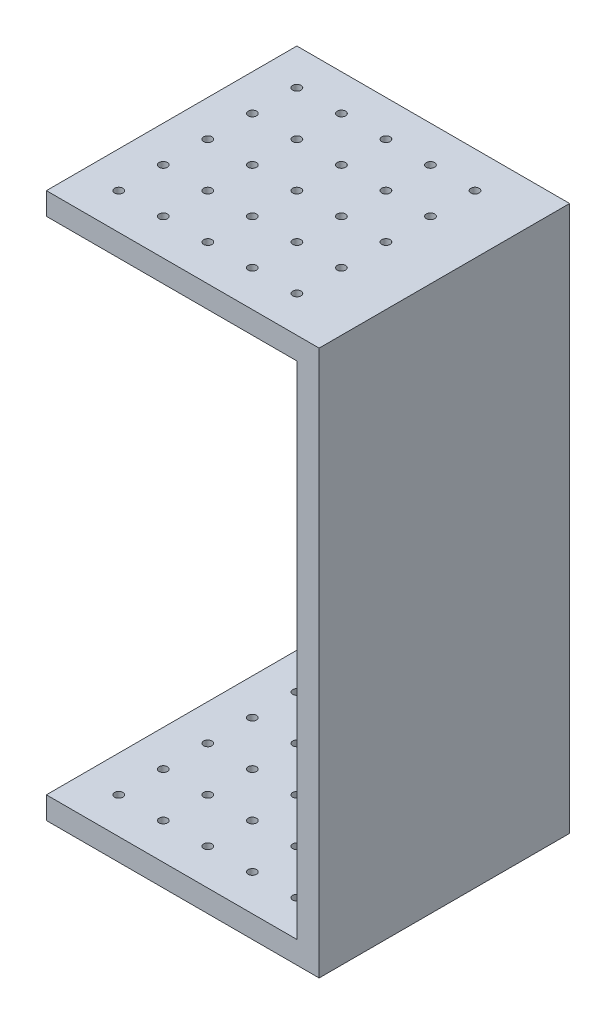
from build123d import *

# Parameters (mm, degrees)
SKETCH1_W            = 24.5
SKETCH1_H            = 22.5
BOSS_EXTRUDE1_DEPTH  = 2
SKETCH2_W            = 2
SKETCH2_H            = 22.5
BOSS_EXTRUDE2_DEPTH  = 45
SKETCH4_W            = 24.5
SKETCH4_H            = 22.5
BOSS_EXTRUDE3_DEPTH  = 2
SKETCH3_R            = 0.375
CUT_EXTRUDE1_DEPTH   = 50
LPATTERN1_COUNT      = 5
LPATTERN1_PITCH      = 4
LPATTERN1_COUNT_DIR2 = 5
LPATTERN1_PITCH_DIR2 = 4


with BuildPart() as part:
    # Sketch1 → Boss-Extrude1 (new body)
    with BuildSketch(Plane(origin=(0, 0, 0), x_dir=(1, 0, 0), z_dir=(0, 1, 0))):
        Rectangle(SKETCH1_W, SKETCH1_H)
    extrude(amount=BOSS_EXTRUDE1_DEPTH)

    # Sketch2 → Boss-Extrude2 (add)
    with BuildSketch(Plane(origin=(0, 2, 0), x_dir=(1, 0, 0), z_dir=(0, 1, 0))):
        with Locations((11.25, 0)):
            Rectangle(SKETCH2_W, SKETCH2_H)
    extrude(amount=BOSS_EXTRUDE2_DEPTH)

    # Sketch4 → Boss-Extrude3 (add)
    with BuildSketch(Plane(origin=(0, 47, 0), x_dir=(1, 0, 0), z_dir=(0, 1, 0))):
        Rectangle(SKETCH4_W, SKETCH4_H)
    extrude(amount=BOSS_EXTRUDE3_DEPTH)

    # Sketch3 → Cut-Extrude1 (cut, through all)
    with BuildSketch(Plane.XZ):
        with Locations((-9, 8)):
            Circle(SKETCH3_R)
    cut_extrude1 = extrude(amount=-CUT_EXTRUDE1_DEPTH, mode=Mode.SUBTRACT)

    # LPattern1: Cut-Extrude1 5 × 5
    with Locations(*[(j * LPATTERN1_PITCH_DIR2, 0, -i * LPATTERN1_PITCH) for i in range(LPATTERN1_COUNT) for j in range(LPATTERN1_COUNT_DIR2) if (i, j) != (0, 0)]):
        add(cut_extrude1, mode=Mode.SUBTRACT)


solid = part.part
